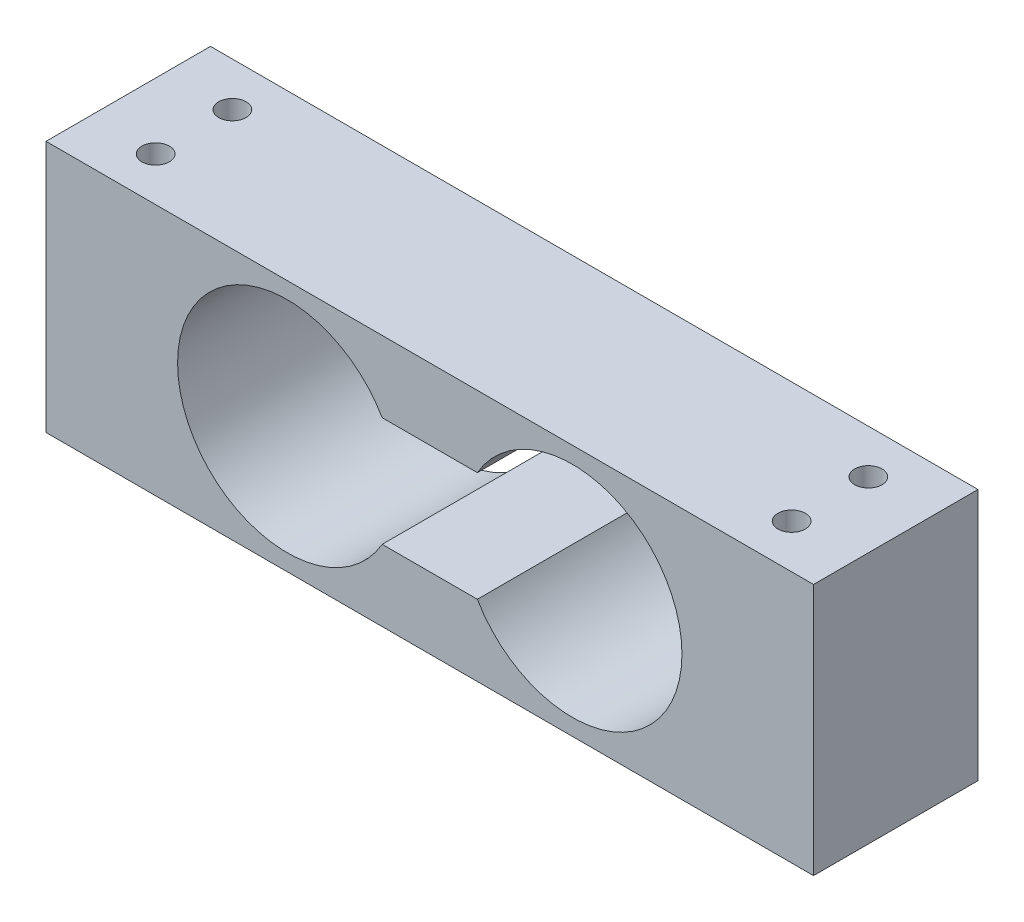
from build123d import *

# Parameters (mm, degrees)
ESQUISSE1_W           = 70
ESQUISSE1_H           = 23
EXTRUSION1_DEPTH      = 7.5
TROU_TARAUD_M3X0_51_D = 2.5


with BuildPart() as part:
    # Esquisse1 → Extrusion1 (new body, symmetric)
    with BuildSketch(Plane.XY):
        with Locations((-35, 11.5)):
            Rectangle(ESQUISSE1_W, ESQUISSE1_H)
        with BuildLine():
            Line((-39.339745962, 16.5), (-30.660254038, 16.5))
            ThreePointArc((-30.660254038, 16.5), (-12, 11.5), (-30.660254038, 6.5))
            Line((-30.660254038, 6.5), (-39.339745962, 6.5))
            ThreePointArc((-39.339745962, 6.5), (-58, 11.5), (-39.339745962, 16.5))
        make_face(mode=Mode.SUBTRACT)
    extrude(amount=EXTRUSION1_DEPTH, both=True)

    # Trou taraudé M3x0.51 (through all)
    with Locations(Plane(origin=(-64, 23, -3.5), x_dir=(1, 0, 0), z_dir=(0, 1, 0))):
        with Locations((0, 0), (0, -7), (58, 0), (58, -7)):
            Hole(TROU_TARAUD_M3X0_51_D / 2)


solid = part.part
